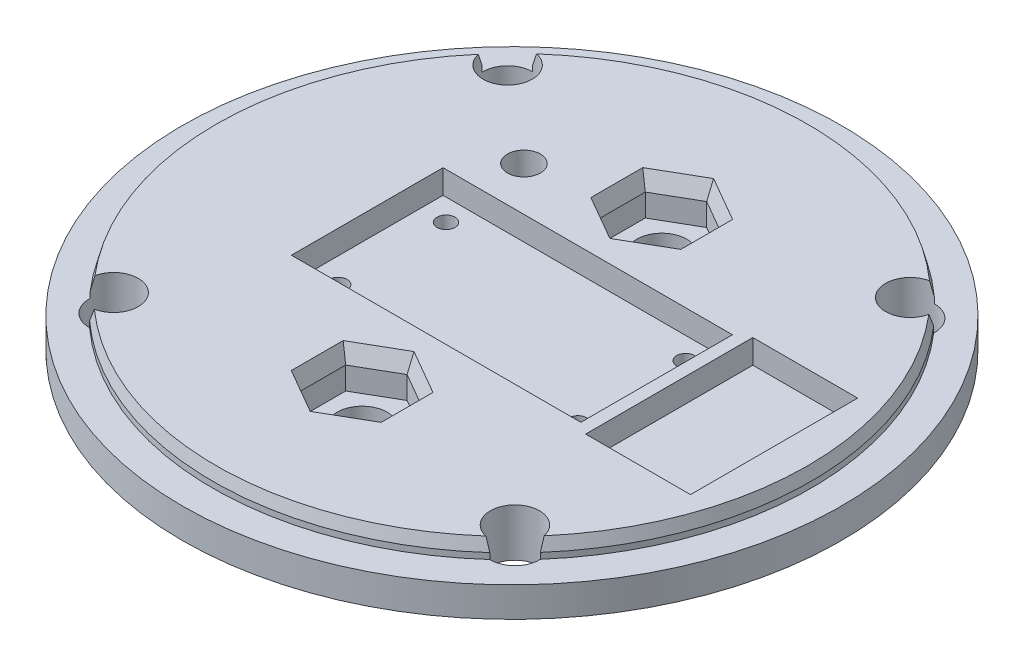
from build123d import *

# Parameters (mm, degrees)
SKETCH_1_R            = 55
EXTRUDE_1_DEPTH       = 5
SKETCH_2_R            = 49.9
EXTRUDE_2_DEPTH       = 3
SKETCH_3_W            = 35
SKETCH_3_H            = 30
EXTRUDE_3_DEPTH       = 25
SKETCH_5_R            = 4.1
CUT_EXTRUDE_2_DEPTH   = 9
SKETCH_6_R            = 2.75
CUT_EXTRUDE_3_DEPTH   = 34
SKETCH2_W             = 20.25
SKETCH2_H             = 10.35
CUT_EXTRUDE1_DEPTH    = 73.5
SKETCH3_W             = 17.5
SKETCH3_H             = 27.9
SKETCH3_W_2           = 48.3
SKETCH3_H_2           = 25.3
CUT_EXTRUDE2_DEPTH    = 4
CHAMFER1_SIZE         = 2
CHAMFER1_SIZE2        = 0.535898385
CHAMFER1_PART_2_SIZE  = 2
CHAMFER1_PART_2_SIZE2 = 0.535898385
CHAMFER1_PART_3_SIZE  = 2
CHAMFER1_PART_3_SIZE2 = 0.535898385
CHAMFER1_PART_4_SIZE  = 2
CHAMFER1_PART_4_SIZE2 = 0.535898385
SKETCH4_W             = 35
SKETCH4_H             = 30
CUT_EXTRUDE3_DEPTH    = 12.5
BOSS_EXTRUDE2_START   = -2
SKETCH5_W             = 20
SKETCH5_H             = 70
BOSS_EXTRUDE2_DEPTH   = 5.325
SKETCH6_R             = 4.15
CUT_EXTRUDE4_DEPTH    = 14.3250001
CUT_EXTRUDE5_DEPTH    = 6.5
CHAMFER2_SIZE         = 1
CHAMFER2_SIZE2        = 2.747477419
SKETCH8_R             = 1.5
CUT_EXTRUDE6_DEPTH    = 17.5


with BuildPart() as part:
    # Эскиз1 → Бобышка-Вытянуть1 (new body)
    with BuildSketch(Plane(origin=(0, 0, 0), x_dir=(1, 0, 0), z_dir=(0, 1, 0))):
        with Locations(Location((0, 0, 0), (0, 0, 270))):  # turned: the seam where the file's is
            Circle(SKETCH_1_R)
    extrude(amount=EXTRUDE_1_DEPTH)

    # Эскиз2 → Бобышка-Вытянуть2 (add)
    with BuildSketch(Plane(origin=(0, 5, 0), x_dir=(1, 0, 0), z_dir=(0, 1, 0))):
        with Locations(Location((0, 0, 0), (0, 0, 270))):  # turned: the seam where the file's is
            Circle(SKETCH_2_R)
    extrude(amount=EXTRUDE_2_DEPTH)

    # Эскиз3 → Бобышка-Вытянуть3 (add)
    with BuildSketch(Plane.XZ):
        Rectangle(SKETCH_3_W, SKETCH_3_H)
    extrude(amount=EXTRUDE_3_DEPTH)

    # Эскиз5 → Вырез-Вытянуть2 (cut, through all)
    with BuildSketch(Plane.XZ):
        with Locations(Location((33.592198598, -32.871936263, 0), (0, 0, 270))):  # turned: the seam where the file's is
            Circle(SKETCH_5_R)
        with Locations(Location((-33.591727056, -32.872418125, 0), (0, 0, 270))):  # turned: the seam where the file's is
            Circle(SKETCH_5_R)
        with Locations(Location((-33.591727056, 32.872418125, 0), (0, 0, 270))):  # turned: the seam where the file's is
            Circle(SKETCH_5_R)
        with Locations(Location((33.483215177, 32.983215177, 0), (0, 0, 270))):  # turned: the seam where the file's is
            Circle(SKETCH_5_R)
    extrude(amount=-CUT_EXTRUDE_2_DEPTH, mode=Mode.SUBTRACT)

    # Эскиз6 → Вырез-Вытянуть3 (cut, through all)
    with BuildSketch(Plane(origin=(0, 8, 0), x_dir=(1, 0, 0), z_dir=(0, 1, 0))):
        with Locations(Location((-17.999856554, 19.999999999, 0), (0, 0, 270))):  # turned: the seam where the file's is
            Circle(SKETCH_6_R)
    extrude(amount=-CUT_EXTRUDE_3_DEPTH, mode=Mode.SUBTRACT)

    # Sketch2 → Cut-Extrude1 (cut, through all)
    with BuildSketch(Plane.ZY.offset(17.5)):
        with Locations((0, -12.5)):
            Rectangle(SKETCH2_W, SKETCH2_H)
    extrude(amount=-CUT_EXTRUDE1_DEPTH, mode=Mode.SUBTRACT)

    # Sketch3 → Cut-Extrude2 (cut)
    with BuildSketch(Plane(origin=(0, 8, 0), x_dir=(1, 0, 0), z_dir=(0, 1, 0))):
        with Locations((35, 0)):
            Rectangle(SKETCH3_W, SKETCH3_H)
        Rectangle(SKETCH3_W_2, SKETCH3_H_2)
    extrude(amount=-CUT_EXTRUDE2_DEPTH, mode=Mode.SUBTRACT)

    # Chamfer1
    chamfer1_edges = [part.edges().sort_by_distance(p)[0] for p in [
        (0.000357897, 8, -49.899999999),
    ]]
    chamfer1_side = [part.faces().sort_by_distance(p)[0] for p in [
        (0.000357897, 6.5, -49.899999999),
    ]]
    chamfer(chamfer1_edges, length=CHAMFER1_SIZE, length2=CHAMFER1_SIZE2, reference=chamfer1_side[0])

    # Chamfer1 part 2
    chamfer1_part_2_edges = [part.edges().sort_by_distance(p)[0] for p in [
        (-49.9, 8, 0),
    ]]
    chamfer1_part_2_side = [part.faces().sort_by_distance(p)[0] for p in [
        (-49.9, 6.5, 0),
    ]]
    chamfer(chamfer1_part_2_edges, length=CHAMFER1_PART_2_SIZE, length2=CHAMFER1_PART_2_SIZE2, reference=chamfer1_part_2_side[0])

    # Chamfer1 part 3
    chamfer1_part_3_edges = [part.edges().sort_by_distance(p)[0] for p in [
        (-0.08242255, 8, 49.899931929),
    ]]
    chamfer1_part_3_side = [part.faces().sort_by_distance(p)[0] for p in [
        (-0.08242255, 6.5, 49.899931929),
    ]]
    chamfer(chamfer1_part_3_edges, length=CHAMFER1_PART_3_SIZE, length2=CHAMFER1_PART_3_SIZE2, reference=chamfer1_part_3_side[0])

    # Chamfer1 part 4
    chamfer1_part_4_edges = [part.edges().sort_by_distance(p)[0] for p in [
        (49.899931657, 8, 0.082587101),
    ]]
    chamfer1_part_4_side = [part.faces().sort_by_distance(p)[0] for p in [
        (49.899931657, 6.5, 0.082587101),
    ]]
    chamfer(chamfer1_part_4_edges, length=CHAMFER1_PART_4_SIZE, length2=CHAMFER1_PART_4_SIZE2, reference=chamfer1_part_4_side[0])

    # Sketch4 → Cut-Extrude3 (cut)
    with BuildSketch(Plane.XZ.offset(25)):
        Rectangle(SKETCH4_W, SKETCH4_H)
    extrude(amount=-CUT_EXTRUDE3_DEPTH, mode=Mode.SUBTRACT)

    # Sketch5 → Boss-Extrude2 (add)
    with BuildSketch(Plane.XZ.offset(7.325).offset(BOSS_EXTRUDE2_START)):
        Rectangle(SKETCH5_W, SKETCH5_H)
    extrude(amount=-BOSS_EXTRUDE2_DEPTH)

    # Sketch6 → Cut-Extrude4 (cut, through all)
    with BuildSketch(Plane.XZ.offset(5.325)):
        with Locations(Location((0, 25, 0), (0, 0, 270))):  # turned: the seam where the file's is
            Circle(SKETCH6_R)
        with Locations(Location((0, -25, 0), (0, 0, 270))):  # turned: the seam where the file's is
            Circle(SKETCH6_R)
    extrude(amount=-CUT_EXTRUDE4_DEPTH, mode=Mode.SUBTRACT)

    # Sketch7 → Cut-Extrude5 (cut)
    with BuildSketch(Plane(origin=(0, 8, 0), x_dir=(1, 0, 0), z_dir=(0, 1, 0))):
        Polygon((0, -32.5), (6.495190528, -28.75), (6.495190528, -21.25), (0, -17.5), (-6.495190528, -21.25), (-6.495190528, -28.75), align=None)
        Polygon((0, 17.5), (6.495190528, 21.25), (6.495190528, 28.75), (0, 32.5), (-6.495190528, 28.75), (-6.495190528, 21.25), align=None)
    extrude(amount=-CUT_EXTRUDE5_DEPTH, mode=Mode.SUBTRACT)

    # Chamfer2
    chamfer2_edges = [part.edges().sort_by_distance(p)[0] for p in [
        (-3.247595264, 8, 30.625),
        (3.247595264, 8, 30.625),
        (6.495190528, 8, 25),
        (3.247595264, 8, 19.375),
        (-3.247595264, 8, 19.375),
        (-6.495190528, 8, 25),
        (-3.247595264, 8, -19.375),
        (3.247595264, 8, -19.375),
        (6.495190528, 8, -25),
        (3.247595264, 8, -30.625),
        (-3.247595264, 8, -30.625),
        (-6.495190528, 8, -25),
    ]]
    chamfer2_side = [part.faces().sort_by_distance(p)[0] for p in [
        (36.933184569, 8, 28.704637204),
    ]]
    chamfer(chamfer2_edges, length=CHAMFER2_SIZE, length2=CHAMFER2_SIZE2, reference=chamfer2_side[0])

    # Sketch8 → Cut-Extrude6 (cut, through all)
    with BuildSketch(Plane(origin=(0, 4, 0), x_dir=(1, 0, 0), z_dir=(0, 1, 0))):
        with Locations(Location((20, 9, 0), (0, 0, 270))):  # turned: the seam where the file's is
            Circle(SKETCH8_R)
        with Locations(Location((20, -9, 0), (0, 0, 270))):  # turned: the seam where the file's is
            Circle(SKETCH8_R)
        with Locations(Location((-20, 9, 0), (0, 0, 270))):  # turned: the seam where the file's is
            Circle(SKETCH8_R)
        with Locations(Location((-20, -9, 0), (0, 0, 270))):  # turned: the seam where the file's is
            Circle(SKETCH8_R)
    extrude(amount=-CUT_EXTRUDE6_DEPTH, mode=Mode.SUBTRACT)


solid = part.part
